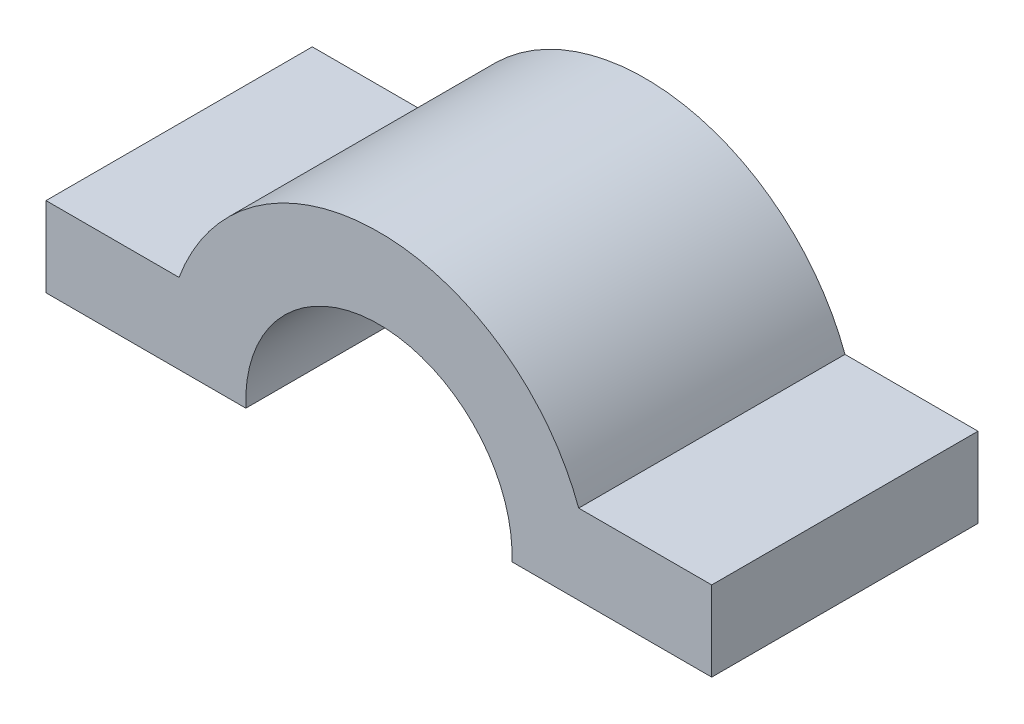
from build123d import *

# Parameters (mm, degrees)
BOSS_EXTRUDE1_DEPTH = 254


with BuildPart() as part:
    # Sketch1 → Boss-Extrude1 (new body)
    with BuildSketch(Plane.XY):
        with BuildLine():
            Line((0, 0), (190.632291842, 0))
            Line((190.632291842, 0), (190.632291842, 76.2))
            Line((190.632291842, 76.2), (63.745532682, 76.2))
            ThreePointArc((63.745532682, 76.2), (-126.867708158, 208.995224478), (-317.480948998, 76.2))
            Line((-317.480948998, 76.2), (-444.367708158, 76.2))
            Line((-444.367708158, 76.2), (-444.367708158, 0))
            Line((-444.367708158, 0), (-253.735416316, 0))
            ThreePointArc((-253.735416316, 0), (-126.867708158, 132.795224478), (0, 0))
        make_face()
    extrude(amount=-BOSS_EXTRUDE1_DEPTH)


solid = part.part
